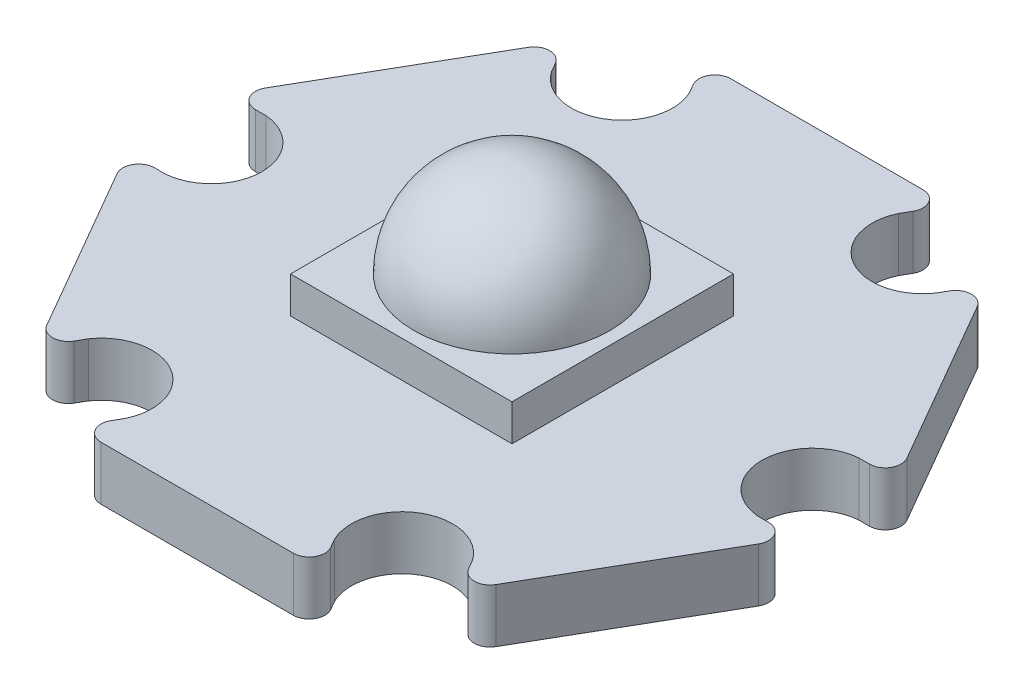
from build123d import *

# Parameters (mm, degrees)
BOSS_EXTRUDE1_DEPTH = 1.7
FILLET1_R           = 0.5
SKETCH4_W           = 7
SKETCH4_H           = 7
BOSS_EXTRUDE2_DEPTH = 1.15
REVOLVE4_ANGLE      = 180


with BuildPart() as part:
    # Sketch1 → Boss-Extrude1 (new body)
    with BuildSketch(Plane(origin=(0, 0, 0), x_dir=(1, 0, 0), z_dir=(0, 1, 0))):
        with BuildLine():
            Line((6.665114398, -8.355683224), (10.568791137, -1.594316776))
            Line((10.568791137, -1.594316776), (9.365263158, -1.594316776))
            ThreePointArc((9.365263158, -1.594316776), (7.9, 0), (9.365263158, 1.594316776))
            Line((9.365263158, 1.594316776), (10.568791137, 1.594316776))
            Line((10.568791137, 1.594316776), (6.665114398, 8.355683224))
            Line((6.665114398, 8.355683224), (6.063350409, 7.31339742))
            ThreePointArc((6.063350409, 7.31339742), (3.95, 6.84160069), (3.301912749, 8.907714196))
            Line((3.301912749, 8.907714196), (3.903676738, 9.95))
            Line((3.903676738, 9.95), (-3.903676738, 9.95))
            Line((-3.903676738, 9.95), (-3.301912749, 8.907714196))
            ThreePointArc((-3.301912749, 8.907714196), (-3.95, 6.84160069), (-6.063350409, 7.31339742))
            Line((-6.063350409, 7.31339742), (-6.665114398, 8.355683224))
            Line((-6.665114398, 8.355683224), (-10.568791137, 1.594316776))
            Line((-10.568791137, 1.594316776), (-9.365263158, 1.594316776))
            ThreePointArc((-9.365263158, 1.594316776), (-7.9, 0), (-9.365263158, -1.594316776))
            Line((-9.365263158, -1.594316776), (-10.568791137, -1.594316776))
            Line((-10.568791137, -1.594316776), (-6.665114398, -8.355683224))
            Line((-6.665114398, -8.355683224), (-6.063350409, -7.31339742))
            ThreePointArc((-6.063350409, -7.31339742), (-3.95, -6.84160069), (-3.301912749, -8.907714196))
            Line((-3.301912749, -8.907714196), (-3.903676738, -9.95))
            Line((-3.903676738, -9.95), (3.903676738, -9.95))
            Line((3.903676738, -9.95), (3.301912749, -8.907714196))
            ThreePointArc((3.301912749, -8.907714196), (3.95, -6.84160069), (6.063350409, -7.31339742))
            Line((6.063350409, -7.31339742), (6.665114398, -8.355683224))
        make_face()
    extrude(amount=BOSS_EXTRUDE1_DEPTH)

    # Fillet1
    fillet1_edges = [part.edges().sort_by_distance(p)[0] for p in [
        (-6.665114398, 0.85, 8.355683224),
        (-10.568791137, 0.85, 1.594316776),
        (-10.568791137, 0.85, -1.594316776),
        (-6.665114398, 0.85, -8.355683224),
        (-3.903676738, 0.85, -9.95),
        (3.903676738, 0.85, -9.95),
        (6.665114398, 0.85, -8.355683224),
        (10.568791137, 0.85, -1.594316776),
        (10.568791137, 0.85, 1.594316776),
        (6.665114398, 0.85, 8.355683224),
        (3.903676738, 0.85, 9.95),
        (-3.903676738, 0.85, 9.95),
    ]]
    fillet(fillet1_edges, radius=FILLET1_R)

    # Sketch4 → Boss-Extrude2 (add)
    with BuildSketch(Plane(origin=(0, 1.7, 0), x_dir=(1, 0, 0), z_dir=(0, 1, 0))):
        Rectangle(SKETCH4_W, SKETCH4_H)
    extrude(amount=BOSS_EXTRUDE2_DEPTH)

    # Sketch5 → Revolve4 (revolve)
    with BuildSketch(Plane(origin=(0, 2.85, 0), x_dir=(1, 0, 0), z_dir=(0, 1, 0))):
        with BuildLine():
            Line((0, 3.1), (0, -3.1))
            ThreePointArc((0, -3.1), (3.1, 0), (0, 3.1))
        make_face()
    revolve(axis=Axis((0, 2.85, -3.1), (0, 0, 1)), revolution_arc=REVOLVE4_ANGLE)


solid = part.part
